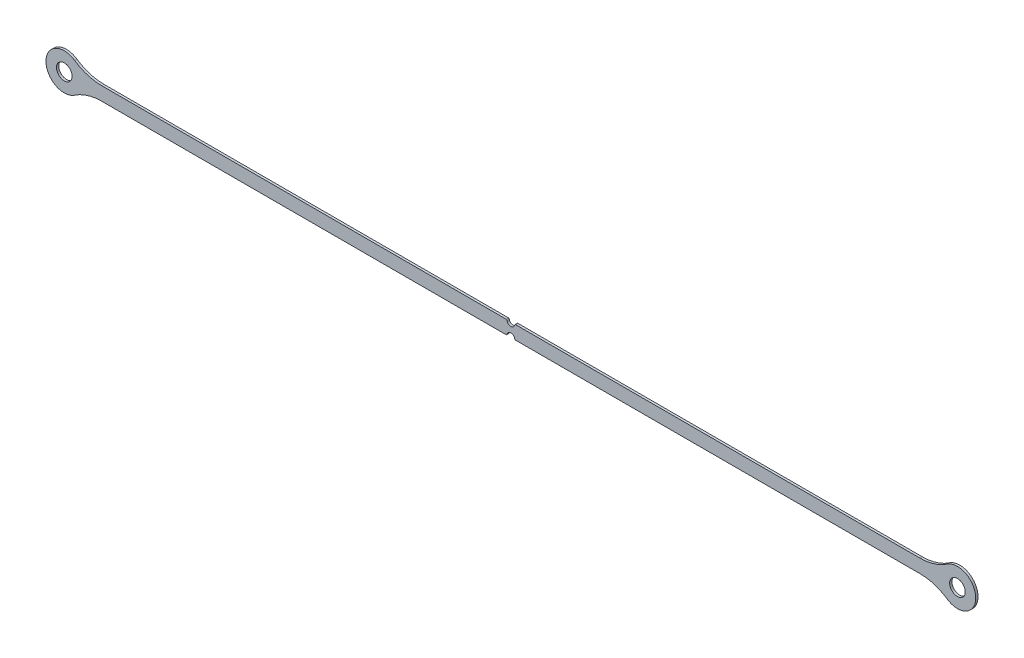
from build123d import *

# Parameters (mm, degrees)
SKETCH1_R           = 4.05
BOSS_EXTRUDE1_DEPTH = 1.2


with BuildPart() as part:
    # Sketch1 → Boss-Extrude1 (new body)
    with BuildSketch(Plane.XY):
        with BuildLine():
            Line((2.50049995, 3.5), (212.557777905, 3.5))
            ThreePointArc((212.557777905, 3.5), (219.929875713, 4.611672852), (226.64634464, 7.847826087))
            ThreePointArc((226.64634464, 7.847826087), (241.5, 0), (226.64634464, -7.847826087))
            ThreePointArc((226.64634464, -7.847826087), (219.929875713, -4.611672852), (212.557777905, -3.5))
            Line((212.557777905, -3.5), (2.50049995, -3.5))
            ThreePointArc((2.50049995, -3.5), (2.183498063, -3.386664976), (2.010205842, -3.098039216))
            ThreePointArc((2.010205842, -3.098039216), (0, -1.45), (-2.010205842, -3.098039216))
            ThreePointArc((-2.010205842, -3.098039216), (-2.183498063, -3.386664976), (-2.50049995, -3.5))
            Line((-2.50049995, -3.5), (-212.557777905, -3.5))
            ThreePointArc((-212.557777905, -3.5), (-219.929875713, -4.611672852), (-226.64634464, -7.847826087))
            ThreePointArc((-226.64634464, -7.847826087), (-241.5, 0), (-226.64634464, 7.847826087))
            ThreePointArc((-226.64634464, 7.847826087), (-219.929875713, 4.611672852), (-212.557777905, 3.5))
            Line((-212.557777905, 3.5), (-2.50049995, 3.5))
            ThreePointArc((-2.50049995, 3.5), (-2.183498063, 3.386664976), (-2.010205842, 3.098039216))
            ThreePointArc((-2.010205842, 3.098039216), (0, 1.45), (2.010205842, 3.098039216))
            ThreePointArc((2.010205842, 3.098039216), (2.183498063, 3.386664976), (2.50049995, 3.5))
        make_face()
        with Locations((232, 0)):
            Circle(SKETCH1_R, mode=Mode.SUBTRACT)
        with Locations((-232, 0)):
            Circle(SKETCH1_R, mode=Mode.SUBTRACT)
    extrude(amount=BOSS_EXTRUDE1_DEPTH)


solid = part.part
